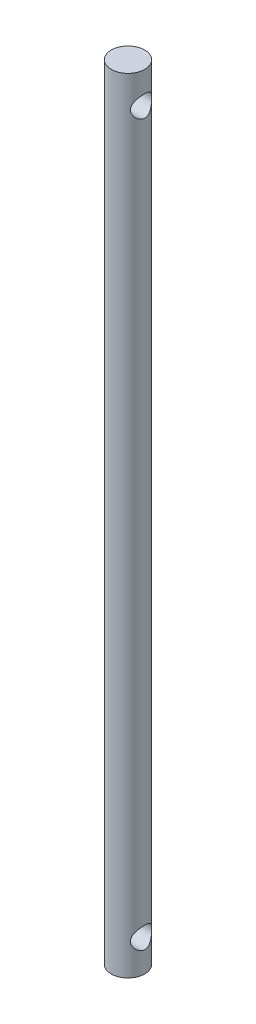
from build123d import *

# Parameters (mm, degrees)
SKETCH1_R                      = 1.5875
BOSS_EXTRUDE1_DEPTH            = 74.2
CUT_EXTRUDE1_REACH             = 3.587
SKETCH2_R                      = 1
CUT_EXTRUDE1_DIRECTION_2_REACH = 3.587


with BuildPart() as part:
    # Sketch1 → Boss-Extrude1 (new body)
    with BuildSketch(Plane(origin=(0, 0, 0), x_dir=(1, 0, 0), z_dir=(0, 1, 0))):
        Circle(SKETCH1_R)
    extrude(amount=BOSS_EXTRUDE1_DEPTH)

    # Sketch2 → Cut-Extrude1 (cut, up to next)
    with BuildSketch(Plane(origin=(0, 0, 0), x_dir=(0, 0, -1), z_dir=(1, 0, 0)), mode=Mode.PRIVATE) as cut_extrude1_sk1:
        with Locations((0, 71.2)):
            Circle(SKETCH2_R)
    cut_extrude1_tool1 = extrude(cut_extrude1_sk1.sketch, amount=-CUT_EXTRUDE1_REACH, mode=Mode.PRIVATE) & part.part
    add(cut_extrude1_tool1.solids().sort_by_distance((0, 71.2, 0))[0], mode=Mode.SUBTRACT)
    # Sketch2 → Cut-Extrude1 (cut, up to next)
    with BuildSketch(Plane(origin=(0, 0, 0), x_dir=(0, 0, -1), z_dir=(1, 0, 0)), mode=Mode.PRIVATE) as cut_extrude1_sk2:
        with Locations((0, 3)):
            Circle(SKETCH2_R)
    cut_extrude1_tool2 = extrude(cut_extrude1_sk2.sketch, amount=-CUT_EXTRUDE1_REACH, mode=Mode.PRIVATE) & part.part
    add(cut_extrude1_tool2.solids().sort_by_distance((0, 3, 0))[0], mode=Mode.SUBTRACT)

    # Sketch2 → Cut-Extrude1 direction 2 (cut, up to next)
    with BuildSketch(Plane(origin=(0, 0, 0), x_dir=(0, 0, -1), z_dir=(1, 0, 0)), mode=Mode.PRIVATE) as cut_extrude1_direction_2_sk1:
        with Locations((0, 71.2)):
            Circle(SKETCH2_R)
    cut_extrude1_direction_2_tool1 = extrude(cut_extrude1_direction_2_sk1.sketch, amount=CUT_EXTRUDE1_DIRECTION_2_REACH, mode=Mode.PRIVATE) & part.part
    add(cut_extrude1_direction_2_tool1.solids().sort_by_distance((0, 71.2, 0))[0], mode=Mode.SUBTRACT)
    # Sketch2 → Cut-Extrude1 direction 2 (cut, up to next)
    with BuildSketch(Plane(origin=(0, 0, 0), x_dir=(0, 0, -1), z_dir=(1, 0, 0)), mode=Mode.PRIVATE) as cut_extrude1_direction_2_sk2:
        with Locations((0, 3)):
            Circle(SKETCH2_R)
    cut_extrude1_direction_2_tool2 = extrude(cut_extrude1_direction_2_sk2.sketch, amount=CUT_EXTRUDE1_DIRECTION_2_REACH, mode=Mode.PRIVATE) & part.part
    add(cut_extrude1_direction_2_tool2.solids().sort_by_distance((0, 3, 0))[0], mode=Mode.SUBTRACT)


solid = part.part
